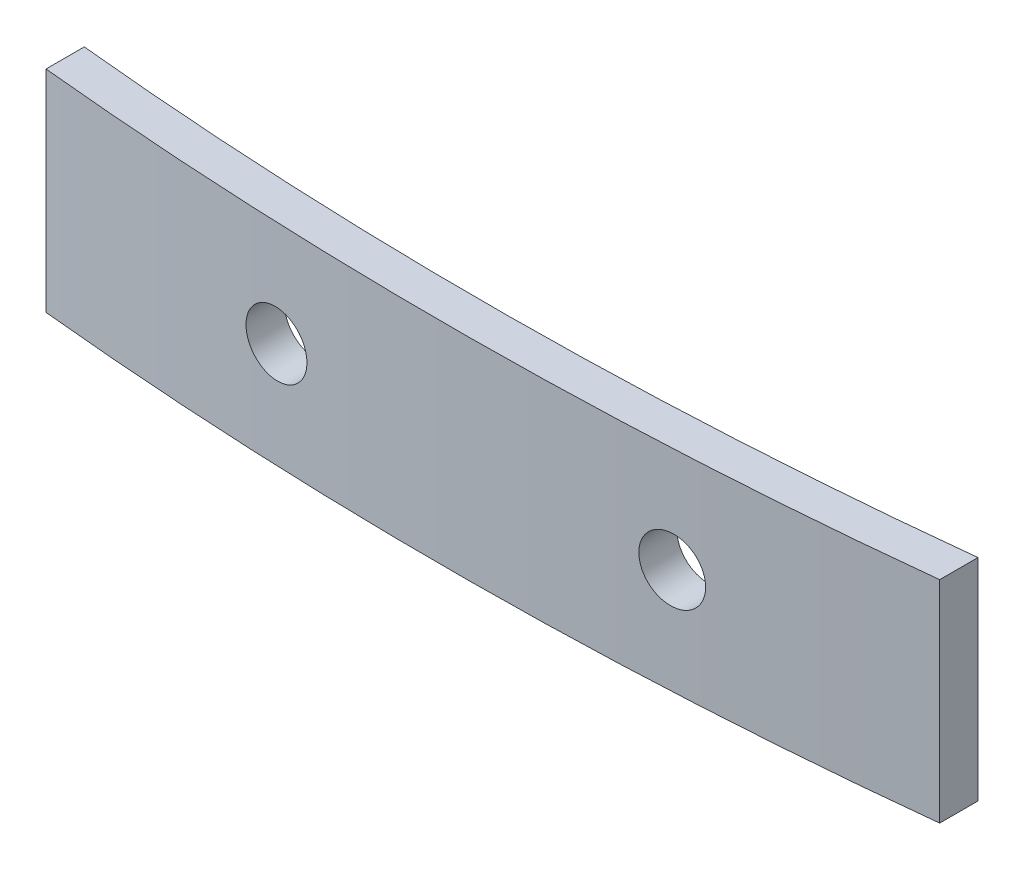
from build123d import *

# Parameters (mm, degrees)
BOSS_EXTRUDE1_DEPTH     = 8.3
SKETCH2_R               = 1.25
CUT_EXTRUDE1_DEPTH      = 5.200074126
CUT_EXTRUDE1_DEPTH_BACK = 1


with BuildPart() as part:
    # Sketch1 → Boss-Extrude1 (new body)
    with BuildSketch(Plane(origin=(0, 0, 0), x_dir=(1, 0, 0), z_dir=(0, 1, 0))):
        with BuildLine():
            Line((17.5, -1.688491505), (17.5, -3.197539453))
            ThreePointArc((17.5, -3.197539453), (0.004691245, -4.197832745), (-17.5, -3.377955009))
            Line((-17.5, -3.377955009), (-17.5, -1.870543406))
            ThreePointArc((-17.5, -1.870543406), (0.004776494, -2.697812194), (17.5, -1.688491505))
        make_face()
    extrude(amount=BOSS_EXTRUDE1_DEPTH)

    # Sketch2 → Cut-Extrude1 (cut, two sides)
    with BuildSketch(Plane.XY) as cut_extrude1_sk:
        with Locations((-7.75, 4.15)):
            Circle(SKETCH2_R)
        with Locations((7.75, 4.15)):
            Circle(SKETCH2_R)
    extrude(amount=CUT_EXTRUDE1_DEPTH, mode=Mode.SUBTRACT)
    extrude(cut_extrude1_sk.sketch, amount=-CUT_EXTRUDE1_DEPTH_BACK, mode=Mode.SUBTRACT)


solid = part.part
